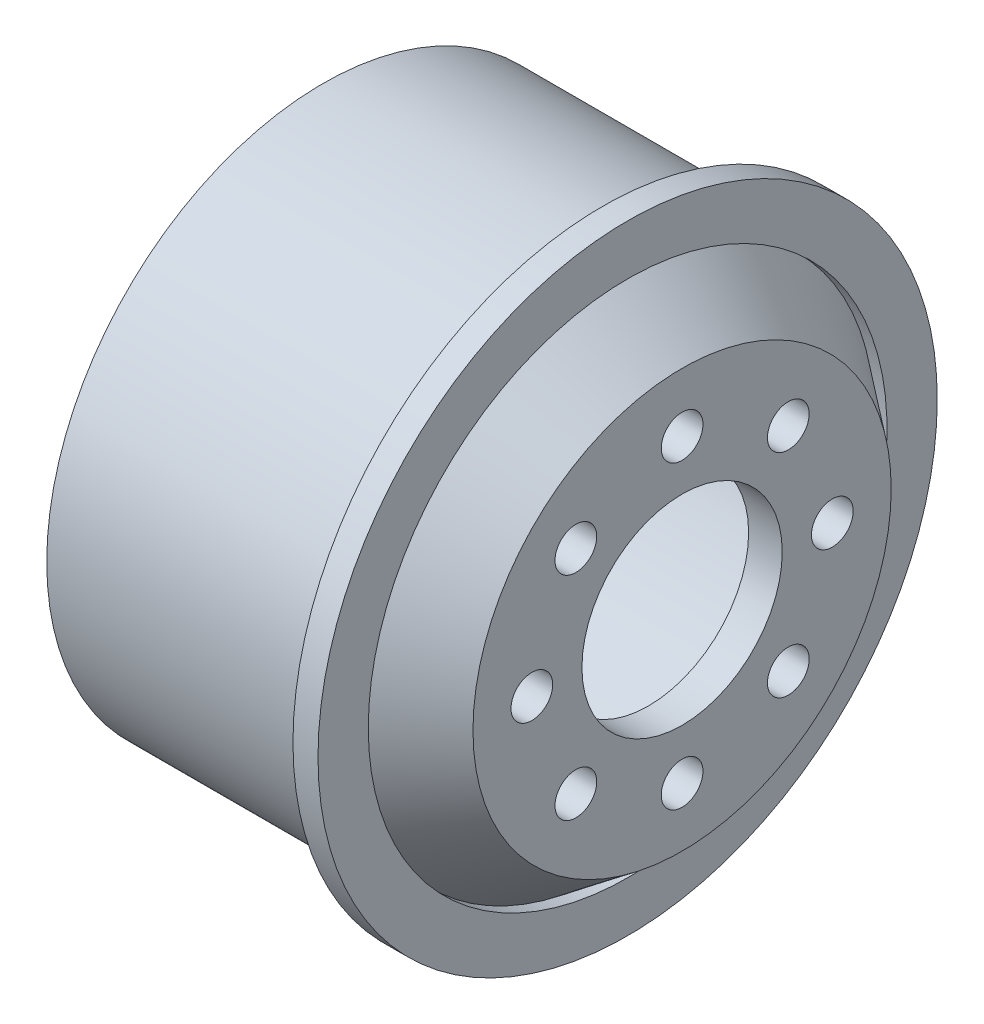
from build123d import *

# Parameters (mm, degrees)
SKETCH2_R          = 1.25
CUT_EXTRUDE1_DEPTH = 22.512750464


with BuildPart() as part:
    # Sketch1 → Revolve1 (revolve)
    with BuildSketch(Plane(origin=(0, 0, 0), x_dir=(1, 0, 0), z_dir=(0, 1, 0))):
        Polygon((-12.563694364, 14.55), (-12.563694364, 16.55), (4.186305636, 16.55), (4.186305636, 18.55), (5.686305636, 18.55), (5.686305636, 15.537968137), (4.955330367, 15.537968137), (8.9490561, 12.528479936), (8.9490561, 6), (6.936305636, 6), (6.936305636, 11.540924884), (2.943128086, 14.55), align=None)
    revolve(axis=Axis((-37.278866169, 0, 0), (1, 0, 0)))

    # Sketch2 → Cut-Extrude1 (cut, through all)
    with BuildSketch(Plane(origin=(8.9490561, 0, 0), x_dir=(0, 0, -1), z_dir=(1, 0, 0))):
        with Locations((0, 9)):
            Circle(SKETCH2_R)
        with Locations((6.363961031, 6.363961031)):
            Circle(SKETCH2_R)
        with Locations((9, 0)):
            Circle(SKETCH2_R)
        with Locations((6.363961031, -6.363961031)):
            Circle(SKETCH2_R)
        with Locations((0, -9)):
            Circle(SKETCH2_R)
        with Locations((-6.363961031, -6.363961031)):
            Circle(SKETCH2_R)
        with Locations((-9, 0)):
            Circle(SKETCH2_R)
        with Locations((-6.363961031, 6.363961031)):
            Circle(SKETCH2_R)
    extrude(amount=-CUT_EXTRUDE1_DEPTH, mode=Mode.SUBTRACT)


solid = part.part
